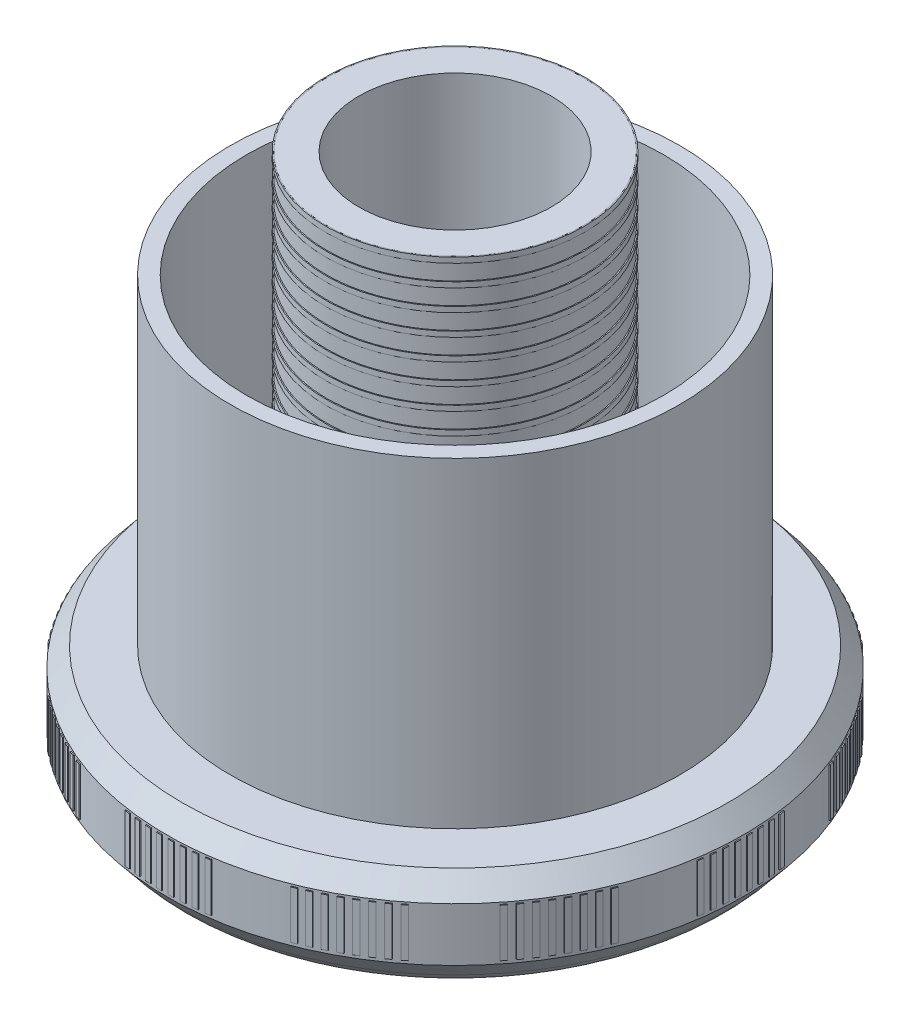
from build123d import *

# Parameters (mm, degrees)
ESQUISSE2_R                          = 12.1
ESQUISSE2_R_2                        = 12
EXTRU_MINCE1_DEPTH                   = 0.5
R_P_TITION_LIN_AIRE1_COUNT           = 19
R_P_TITION_LIN_AIRE1_PITCH           = 2
BOSS_EXTRU_1_START                   = 1.5
BOSS_EXTRU_1_DEPTH                   = 4.5
R_P_TITION_CIRCULAIRE1_COUNT         = 8
R_P_TITION_CIRCULAIRE1_ANGLE         = 16.1
R_P_TITION_CIRCULAIRE2_COUNT         = 12
R_P_TITION_START                     = 1.5
R_P_TITION_CIRCULAIRE2_COPY_1_DEPTH  = 4.5
R_P_TITION_CIRCULAIRE2_COPY_2_DEPTH  = 4.5
R_P_TITION_CIRCULAIRE2_COPY_3_DEPTH  = 4.5
R_P_TITION_CIRCULAIRE2_COPY_4_DEPTH  = 4.5
R_P_TITION_CIRCULAIRE2_COPY_5_DEPTH  = 4.5
R_P_TITION_CIRCULAIRE2_COPY_6_DEPTH  = 4.5
R_P_TITION_CIRCULAIRE2_COPY_7_DEPTH  = 4.5
R_P_TITION_CIRCULAIRE2_COPY_8_DEPTH  = 4.5
R_P_TITION_CIRCULAIRE2_COPY_9_DEPTH  = 4.5
R_P_TITION_CIRCULAIRE2_COPY_10_DEPTH = 4.5
R_P_TITION_CIRCULAIRE2_COPY_11_DEPTH = 4.5
R_P_TITION_CIRCULAIRE2_COPY_12_DEPTH = 4.5
R_P_TITION_CIRCULAIRE2_COPY_13_DEPTH = 4.5
R_P_TITION_CIRCULAIRE2_COPY_14_DEPTH = 4.5
R_P_TITION_CIRCULAIRE2_COPY_15_DEPTH = 4.5
R_P_TITION_CIRCULAIRE2_COPY_16_DEPTH = 4.5
R_P_TITION_CIRCULAIRE2_COPY_17_DEPTH = 4.5
R_P_TITION_CIRCULAIRE2_COPY_18_DEPTH = 4.5
R_P_TITION_CIRCULAIRE2_COPY_19_DEPTH = 4.5
R_P_TITION_CIRCULAIRE2_COPY_20_DEPTH = 4.5
R_P_TITION_CIRCULAIRE2_COPY_21_DEPTH = 4.5
R_P_TITION_CIRCULAIRE2_COPY_22_DEPTH = 4.5
R_P_TITION_CIRCULAIRE2_COPY_23_DEPTH = 4.5
R_P_TITION_CIRCULAIRE2_COPY_24_DEPTH = 4.5
R_P_TITION_CIRCULAIRE2_COPY_25_DEPTH = 4.5
R_P_TITION_CIRCULAIRE2_COPY_26_DEPTH = 4.5
R_P_TITION_CIRCULAIRE2_COPY_27_DEPTH = 4.5
R_P_TITION_CIRCULAIRE2_COPY_28_DEPTH = 4.5
R_P_TITION_CIRCULAIRE2_COPY_29_DEPTH = 4.5
R_P_TITION_CIRCULAIRE2_COPY_30_DEPTH = 4.5
R_P_TITION_CIRCULAIRE2_COPY_31_DEPTH = 4.5
R_P_TITION_CIRCULAIRE2_COPY_32_DEPTH = 4.5
R_P_TITION_CIRCULAIRE2_COPY_33_DEPTH = 4.5
R_P_TITION_CIRCULAIRE2_COPY_34_DEPTH = 4.5
R_P_TITION_CIRCULAIRE2_COPY_35_DEPTH = 4.5
R_P_TITION_CIRCULAIRE2_COPY_36_DEPTH = 4.5
R_P_TITION_CIRCULAIRE2_COPY_37_DEPTH = 4.5
R_P_TITION_CIRCULAIRE2_COPY_38_DEPTH = 4.5
R_P_TITION_CIRCULAIRE2_COPY_39_DEPTH = 4.5
R_P_TITION_CIRCULAIRE2_COPY_40_DEPTH = 4.5
R_P_TITION_CIRCULAIRE2_COPY_41_DEPTH = 4.5
R_P_TITION_CIRCULAIRE2_COPY_42_DEPTH = 4.5
R_P_TITION_CIRCULAIRE2_COPY_43_DEPTH = 4.5
R_P_TITION_CIRCULAIRE2_COPY_44_DEPTH = 4.5
R_P_TITION_CIRCULAIRE2_COPY_45_DEPTH = 4.5
R_P_TITION_CIRCULAIRE2_COPY_46_DEPTH = 4.5
R_P_TITION_CIRCULAIRE2_COPY_47_DEPTH = 4.5
R_P_TITION_CIRCULAIRE2_COPY_48_DEPTH = 4.5
R_P_TITION_CIRCULAIRE2_COPY_49_DEPTH = 4.5
R_P_TITION_CIRCULAIRE2_COPY_50_DEPTH = 4.5
R_P_TITION_CIRCULAIRE2_COPY_51_DEPTH = 4.5
R_P_TITION_CIRCULAIRE2_COPY_52_DEPTH = 4.5
R_P_TITION_CIRCULAIRE2_COPY_53_DEPTH = 4.5
R_P_TITION_CIRCULAIRE2_COPY_54_DEPTH = 4.5
R_P_TITION_CIRCULAIRE2_COPY_55_DEPTH = 4.5
R_P_TITION_CIRCULAIRE2_COPY_56_DEPTH = 4.5
R_P_TITION_CIRCULAIRE2_COPY_57_DEPTH = 4.5
R_P_TITION_CIRCULAIRE2_COPY_58_DEPTH = 4.5
R_P_TITION_CIRCULAIRE2_COPY_59_DEPTH = 4.5
R_P_TITION_CIRCULAIRE2_COPY_60_DEPTH = 4.5
R_P_TITION_CIRCULAIRE2_COPY_61_DEPTH = 4.5
R_P_TITION_CIRCULAIRE2_COPY_62_DEPTH = 4.5
R_P_TITION_CIRCULAIRE2_COPY_63_DEPTH = 4.5
R_P_TITION_CIRCULAIRE2_COPY_64_DEPTH = 4.5
R_P_TITION_CIRCULAIRE2_COPY_65_DEPTH = 4.5
R_P_TITION_CIRCULAIRE2_COPY_66_DEPTH = 4.5
R_P_TITION_CIRCULAIRE2_COPY_67_DEPTH = 4.5
R_P_TITION_CIRCULAIRE2_COPY_68_DEPTH = 4.5
R_P_TITION_CIRCULAIRE2_COPY_69_DEPTH = 4.5
R_P_TITION_CIRCULAIRE2_COPY_70_DEPTH = 4.5
R_P_TITION_CIRCULAIRE2_COPY_71_DEPTH = 4.5
R_P_TITION_CIRCULAIRE2_COPY_72_DEPTH = 4.5
R_P_TITION_CIRCULAIRE2_COPY_73_DEPTH = 4.5
R_P_TITION_CIRCULAIRE2_COPY_74_DEPTH = 4.5
R_P_TITION_CIRCULAIRE2_COPY_75_DEPTH = 4.5
R_P_TITION_CIRCULAIRE2_COPY_76_DEPTH = 4.5
R_P_TITION_CIRCULAIRE2_COPY_77_DEPTH = 4.5


with BuildPart() as part:
    # Esquisse1 → Révolution1 (revolve)
    with BuildSketch(Plane.XY):
        with BuildLine():
            Line((0, 0), (-5, 0))
            Line((-5, 0), (-5, 2))
            Line((-5, 2), (-9, 2))
            Line((-9, 2), (-9, -2))
            Line((-9, -2), (-21, -2))
            Line((-21, -2), (-21, 2))
            Line((-21, 2), (-23, 2))
            Line((-23, 2), (-23, -2))
            ThreePointArc((-23, -2), (-24.418637165, -1.643382037), (-25.5, -0.658312395))
            Line((-25.5, -0.658312395), (-27, 1.170843802))
            Line((-27, 1.170843802), (-27, 6.170843802))
            Line((-27, 6.170843802), (-25.5, 8))
            Line((-25.5, 8), (-21, 8))
            Line((-21, 8), (-21, 38))
            Line((-21, 38), (-19.5, 38))
            Line((-19.5, 38), (-19.5, 8))
            Line((-19.5, 8), (-12, 8))
            Line((-12, 8), (-12, 48))
            Line((-12, 48), (-9, 48))
            Line((-9, 48), (-9, 8))
            Line((-9, 8), (0, 8))
            Line((0, 8), (0, 0))
        make_face()
    revolve(axis=Axis((0, 8, 0), (0, 1, 0)))

    # Esquisse3 → Boss.-Extru.1 (add)
    with BuildSketch(Plane(origin=(0, 0, 0), x_dir=(1, 0, 0), z_dir=(0, 1, 0)).offset(BOSS_EXTRU_1_START)):
        Polygon((-3.975000726, 26.705792803), (-3.989722951, 26.804703147), (-3.494513207, 26.873748854), (-3.481618325, 26.774583729), align=None)
    boss_extru_1 = extrude(amount=BOSS_EXTRU_1_DEPTH)

    # Répétition circulaire1: Boss.-Extru.1 ×8 about axis
    r_p_tition_circulaire1_axis = Axis((0, 6.170843802, 0), (0, -1, 0))
    for i in range(1, R_P_TITION_CIRCULAIRE1_COUNT):
        add(boss_extru_1.rotate(r_p_tition_circulaire1_axis, i * R_P_TITION_CIRCULAIRE1_ANGLE / (R_P_TITION_CIRCULAIRE1_COUNT - 1)))

    # Répétition circulaire2: Boss.-Extru.1 ×12 about axis
    r_p_tition_circulaire2_axis = Axis((0, 8, 0), (0, -1, 0))
    for i in range(1, R_P_TITION_CIRCULAIRE2_COUNT):
        add(boss_extru_1.rotate(r_p_tition_circulaire2_axis, i * 360 / R_P_TITION_CIRCULAIRE2_COUNT))

    # Répétition circulaire2 copy 1 sketch → Répétition circulaire2 copy 1 (add)
    with BuildSketch(Plane(origin=(0, 0, 0), x_dir=(0.8452618332218562, 0, 0.5343523493898263), z_dir=(0, 1, 0)).offset(R_P_TITION_START)):
        Polygon((-3.975000726, 26.705792803), (-3.989722951, 26.804703147), (-3.494513207, 26.873748854), (-3.481618325, 26.774583729), align=None)
    extrude(amount=R_P_TITION_CIRCULAIRE2_COPY_1_DEPTH)

    # Répétition circulaire2 copy 2 sketch → Répétition circulaire2 copy 2 (add)
    with BuildSketch(Plane(origin=(0, 0, 0), x_dir=(0.4648420457246197, 0, 0.8853936257544158), z_dir=(0, 1, 0)).offset(R_P_TITION_START)):
        Polygon((-3.975000726, 26.705792803), (-3.989722951, 26.804703147), (-3.494513207, 26.873748854), (-3.481618325, 26.774583729), align=None)
    extrude(amount=R_P_TITION_CIRCULAIRE2_COPY_2_DEPTH)

    # Répétition circulaire2 copy 3 sketch → Répétition circulaire2 copy 3 (add)
    with BuildSketch(Plane(origin=(0, 0, 0), x_dir=(-0.04013179253255975, 0, 0.999194395114446), z_dir=(0, 1, 0)).offset(R_P_TITION_START)):
        Polygon((-3.975000726, 26.705792803), (-3.989722951, 26.804703147), (-3.494513207, 26.873748854), (-3.481618325, 26.774583729), align=None)
    extrude(amount=R_P_TITION_CIRCULAIRE2_COPY_3_DEPTH)

    # Répétition circulaire2 copy 4 sketch → Répétition circulaire2 copy 4 (add)
    with BuildSketch(Plane(origin=(0, 0, 0), x_dir=(-0.5343523493898262, 0, 0.8452618332218562), z_dir=(0, 1, 0)).offset(R_P_TITION_START)):
        Polygon((-3.975000726, 26.705792803), (-3.989722951, 26.804703147), (-3.494513207, 26.873748854), (-3.481618325, 26.774583729), align=None)
    extrude(amount=R_P_TITION_CIRCULAIRE2_COPY_4_DEPTH)

    # Répétition circulaire2 copy 5 sketch → Répétition circulaire2 copy 5 (add)
    with BuildSketch(Plane(origin=(0, 0, 0), x_dir=(-0.8853936257544159, 0, 0.4648420457246195), z_dir=(0, 1, 0)).offset(R_P_TITION_START)):
        Polygon((-3.975000726, 26.705792803), (-3.989722951, 26.804703147), (-3.494513207, 26.873748854), (-3.481618325, 26.774583729), align=None)
    extrude(amount=R_P_TITION_CIRCULAIRE2_COPY_5_DEPTH)

    # Répétition circulaire2 copy 6 sketch → Répétition circulaire2 copy 6 (add)
    with BuildSketch(Plane(origin=(0, 0, 0), x_dir=(-0.999194395114446, 0, -0.04013179253255969), z_dir=(0, 1, 0)).offset(R_P_TITION_START)):
        Polygon((-3.975000726, 26.705792803), (-3.989722951, 26.804703147), (-3.494513207, 26.873748854), (-3.481618325, 26.774583729), align=None)
    extrude(amount=R_P_TITION_CIRCULAIRE2_COPY_6_DEPTH)

    # Répétition circulaire2 copy 7 sketch → Répétition circulaire2 copy 7 (add)
    with BuildSketch(Plane(origin=(0, 0, 0), x_dir=(-0.8452618332218561, 0, -0.5343523493898266), z_dir=(0, 1, 0)).offset(R_P_TITION_START)):
        Polygon((-3.975000726, 26.705792803), (-3.989722951, 26.804703147), (-3.494513207, 26.873748854), (-3.481618325, 26.774583729), align=None)
    extrude(amount=R_P_TITION_CIRCULAIRE2_COPY_7_DEPTH)

    # Répétition circulaire2 copy 8 sketch → Répétition circulaire2 copy 8 (add)
    with BuildSketch(Plane(origin=(0, 0, 0), x_dir=(-0.46484204572462, 0, -0.8853936257544157), z_dir=(0, 1, 0)).offset(R_P_TITION_START)):
        Polygon((-3.975000726, 26.705792803), (-3.989722951, 26.804703147), (-3.494513207, 26.873748854), (-3.481618325, 26.774583729), align=None)
    extrude(amount=R_P_TITION_CIRCULAIRE2_COPY_8_DEPTH)

    # Répétition circulaire2 copy 9 sketch → Répétition circulaire2 copy 9 (add)
    with BuildSketch(Plane(origin=(0, 0, 0), x_dir=(0.040131792532559635, 0, -0.999194395114446), z_dir=(0, 1, 0)).offset(R_P_TITION_START)):
        Polygon((-3.975000726, 26.705792803), (-3.989722951, 26.804703147), (-3.494513207, 26.873748854), (-3.481618325, 26.774583729), align=None)
    extrude(amount=R_P_TITION_CIRCULAIRE2_COPY_9_DEPTH)

    # Répétition circulaire2 copy 10 sketch → Répétition circulaire2 copy 10 (add)
    with BuildSketch(Plane(origin=(0, 0, 0), x_dir=(0.5343523493898266, 0, -0.8452618332218561), z_dir=(0, 1, 0)).offset(R_P_TITION_START)):
        Polygon((-3.975000726, 26.705792803), (-3.989722951, 26.804703147), (-3.494513207, 26.873748854), (-3.481618325, 26.774583729), align=None)
    extrude(amount=R_P_TITION_CIRCULAIRE2_COPY_10_DEPTH)

    # Répétition circulaire2 copy 11 sketch → Répétition circulaire2 copy 11 (add)
    with BuildSketch(Plane(origin=(0, 0, 0), x_dir=(0.8853936257544157, 0, -0.46484204572462), z_dir=(0, 1, 0)).offset(R_P_TITION_START)):
        Polygon((-3.975000726, 26.705792803), (-3.989722951, 26.804703147), (-3.494513207, 26.873748854), (-3.481618325, 26.774583729), align=None)
    extrude(amount=R_P_TITION_CIRCULAIRE2_COPY_11_DEPTH)

    # Répétition circulaire2 copy 12 sketch → Répétition circulaire2 copy 12 (add)
    with BuildSketch(Plane(origin=(0, 0, 0), x_dir=(0.8231363685344418, 0, 0.5678437450531013), z_dir=(0, 1, 0)).offset(R_P_TITION_START)):
        Polygon((-3.975000726, 26.705792803), (-3.989722951, 26.804703147), (-3.494513207, 26.873748854), (-3.481618325, 26.774583729), align=None)
    extrude(amount=R_P_TITION_CIRCULAIRE2_COPY_12_DEPTH)

    # Répétition circulaire2 copy 13 sketch → Répétition circulaire2 copy 13 (add)
    with BuildSketch(Plane(origin=(0, 0, 0), x_dir=(0.4289351334031458, 0, 0.9033352928633007), z_dir=(0, 1, 0)).offset(R_P_TITION_START)):
        Polygon((-3.975000726, 26.705792803), (-3.989722951, 26.804703147), (-3.494513207, 26.873748854), (-3.481618325, 26.774583729), align=None)
    extrude(amount=R_P_TITION_CIRCULAIRE2_COPY_13_DEPTH)

    # Répétition circulaire2 copy 14 sketch → Répétition circulaire2 copy 14 (add)
    with BuildSketch(Plane(origin=(0, 0, 0), x_dir=(-0.08019892432885903, 0, 0.9967788784562471), z_dir=(0, 1, 0)).offset(R_P_TITION_START)):
        Polygon((-3.975000726, 26.705792803), (-3.989722951, 26.804703147), (-3.494513207, 26.873748854), (-3.481618325, 26.774583729), align=None)
    extrude(amount=R_P_TITION_CIRCULAIRE2_COPY_14_DEPTH)

    # Répétition circulaire2 copy 15 sketch → Répétition circulaire2 copy 15 (add)
    with BuildSketch(Plane(origin=(0, 0, 0), x_dir=(-0.5678437450531012, 0, 0.8231363685344418), z_dir=(0, 1, 0)).offset(R_P_TITION_START)):
        Polygon((-3.975000726, 26.705792803), (-3.989722951, 26.804703147), (-3.494513207, 26.873748854), (-3.481618325, 26.774583729), align=None)
    extrude(amount=R_P_TITION_CIRCULAIRE2_COPY_15_DEPTH)

    # Répétition circulaire2 copy 16 sketch → Répétition circulaire2 copy 16 (add)
    with BuildSketch(Plane(origin=(0, 0, 0), x_dir=(-0.9033352928633008, 0, 0.4289351334031457), z_dir=(0, 1, 0)).offset(R_P_TITION_START)):
        Polygon((-3.975000726, 26.705792803), (-3.989722951, 26.804703147), (-3.494513207, 26.873748854), (-3.481618325, 26.774583729), align=None)
    extrude(amount=R_P_TITION_CIRCULAIRE2_COPY_16_DEPTH)

    # Répétition circulaire2 copy 17 sketch → Répétition circulaire2 copy 17 (add)
    with BuildSketch(Plane(origin=(0, 0, 0), x_dir=(-0.9967788784562471, 0, -0.08019892432885896), z_dir=(0, 1, 0)).offset(R_P_TITION_START)):
        Polygon((-3.975000726, 26.705792803), (-3.989722951, 26.804703147), (-3.494513207, 26.873748854), (-3.481618325, 26.774583729), align=None)
    extrude(amount=R_P_TITION_CIRCULAIRE2_COPY_17_DEPTH)

    # Répétition circulaire2 copy 18 sketch → Répétition circulaire2 copy 18 (add)
    with BuildSketch(Plane(origin=(0, 0, 0), x_dir=(-0.8231363685344417, 0, -0.5678437450531015), z_dir=(0, 1, 0)).offset(R_P_TITION_START)):
        Polygon((-3.975000726, 26.705792803), (-3.989722951, 26.804703147), (-3.494513207, 26.873748854), (-3.481618325, 26.774583729), align=None)
    extrude(amount=R_P_TITION_CIRCULAIRE2_COPY_18_DEPTH)

    # Répétition circulaire2 copy 19 sketch → Répétition circulaire2 copy 19 (add)
    with BuildSketch(Plane(origin=(0, 0, 0), x_dir=(-0.4289351334031462, 0, -0.9033352928633006), z_dir=(0, 1, 0)).offset(R_P_TITION_START)):
        Polygon((-3.975000726, 26.705792803), (-3.989722951, 26.804703147), (-3.494513207, 26.873748854), (-3.481618325, 26.774583729), align=None)
    extrude(amount=R_P_TITION_CIRCULAIRE2_COPY_19_DEPTH)

    # Répétition circulaire2 copy 20 sketch → Répétition circulaire2 copy 20 (add)
    with BuildSketch(Plane(origin=(0, 0, 0), x_dir=(0.0801989243288589, 0, -0.9967788784562471), z_dir=(0, 1, 0)).offset(R_P_TITION_START)):
        Polygon((-3.975000726, 26.705792803), (-3.989722951, 26.804703147), (-3.494513207, 26.873748854), (-3.481618325, 26.774583729), align=None)
    extrude(amount=R_P_TITION_CIRCULAIRE2_COPY_20_DEPTH)

    # Répétition circulaire2 copy 21 sketch → Répétition circulaire2 copy 21 (add)
    with BuildSketch(Plane(origin=(0, 0, 0), x_dir=(0.5678437450531015, 0, -0.8231363685344417), z_dir=(0, 1, 0)).offset(R_P_TITION_START)):
        Polygon((-3.975000726, 26.705792803), (-3.989722951, 26.804703147), (-3.494513207, 26.873748854), (-3.481618325, 26.774583729), align=None)
    extrude(amount=R_P_TITION_CIRCULAIRE2_COPY_21_DEPTH)

    # Répétition circulaire2 copy 22 sketch → Répétition circulaire2 copy 22 (add)
    with BuildSketch(Plane(origin=(0, 0, 0), x_dir=(0.9033352928633006, 0, -0.4289351334031462), z_dir=(0, 1, 0)).offset(R_P_TITION_START)):
        Polygon((-3.975000726, 26.705792803), (-3.989722951, 26.804703147), (-3.494513207, 26.873748854), (-3.481618325, 26.774583729), align=None)
    extrude(amount=R_P_TITION_CIRCULAIRE2_COPY_22_DEPTH)

    # Répétition circulaire2 copy 23 sketch → Répétition circulaire2 copy 23 (add)
    with BuildSketch(Plane(origin=(0, 0, 0), x_dir=(0.7996846584870905, 0, 0.6004202253258842), z_dir=(0, 1, 0)).offset(R_P_TITION_START)):
        Polygon((-3.975000726, 26.705792803), (-3.989722951, 26.804703147), (-3.494513207, 26.873748854), (-3.481618325, 26.774583729), align=None)
    extrude(amount=R_P_TITION_CIRCULAIRE2_COPY_23_DEPTH)

    # Répétition circulaire2 copy 24 sketch → Répétition circulaire2 copy 24 (add)
    with BuildSketch(Plane(origin=(0, 0, 0), x_dir=(0.3923371166035614, 0, 0.9198214973217377), z_dir=(0, 1, 0)).offset(R_P_TITION_START)):
        Polygon((-3.975000726, 26.705792803), (-3.989722951, 26.804703147), (-3.494513207, 26.873748854), (-3.481618325, 26.774583729), align=None)
    extrude(amount=R_P_TITION_CIRCULAIRE2_COPY_24_DEPTH)

    # Répétition circulaire2 copy 25 sketch → Répétition circulaire2 copy 25 (add)
    with BuildSketch(Plane(origin=(0, 0, 0), x_dir=(-0.12013683883464729, 0, 0.9927573419294455), z_dir=(0, 1, 0)).offset(R_P_TITION_START)):
        Polygon((-3.975000726, 26.705792803), (-3.989722951, 26.804703147), (-3.494513207, 26.873748854), (-3.481618325, 26.774583729), align=None)
    extrude(amount=R_P_TITION_CIRCULAIRE2_COPY_25_DEPTH)

    # Répétition circulaire2 copy 26 sketch → Répétition circulaire2 copy 26 (add)
    with BuildSketch(Plane(origin=(0, 0, 0), x_dir=(-0.600420225325884, 0, 0.7996846584870905), z_dir=(0, 1, 0)).offset(R_P_TITION_START)):
        Polygon((-3.975000726, 26.705792803), (-3.989722951, 26.804703147), (-3.494513207, 26.873748854), (-3.481618325, 26.774583729), align=None)
    extrude(amount=R_P_TITION_CIRCULAIRE2_COPY_26_DEPTH)

    # Répétition circulaire2 copy 27 sketch → Répétition circulaire2 copy 27 (add)
    with BuildSketch(Plane(origin=(0, 0, 0), x_dir=(-0.9198214973217378, 0, 0.3923371166035612), z_dir=(0, 1, 0)).offset(R_P_TITION_START)):
        Polygon((-3.975000726, 26.705792803), (-3.989722951, 26.804703147), (-3.494513207, 26.873748854), (-3.481618325, 26.774583729), align=None)
    extrude(amount=R_P_TITION_CIRCULAIRE2_COPY_27_DEPTH)

    # Répétition circulaire2 copy 28 sketch → Répétition circulaire2 copy 28 (add)
    with BuildSketch(Plane(origin=(0, 0, 0), x_dir=(-0.9927573419294455, 0, -0.12013683883464722), z_dir=(0, 1, 0)).offset(R_P_TITION_START)):
        Polygon((-3.975000726, 26.705792803), (-3.989722951, 26.804703147), (-3.494513207, 26.873748854), (-3.481618325, 26.774583729), align=None)
    extrude(amount=R_P_TITION_CIRCULAIRE2_COPY_28_DEPTH)

    # Répétition circulaire2 copy 29 sketch → Répétition circulaire2 copy 29 (add)
    with BuildSketch(Plane(origin=(0, 0, 0), x_dir=(-0.7996846584870904, 0, -0.6004202253258843), z_dir=(0, 1, 0)).offset(R_P_TITION_START)):
        Polygon((-3.975000726, 26.705792803), (-3.989722951, 26.804703147), (-3.494513207, 26.873748854), (-3.481618325, 26.774583729), align=None)
    extrude(amount=R_P_TITION_CIRCULAIRE2_COPY_29_DEPTH)

    # Répétition circulaire2 copy 30 sketch → Répétition circulaire2 copy 30 (add)
    with BuildSketch(Plane(origin=(0, 0, 0), x_dir=(-0.39233711660356174, 0, -0.9198214973217376), z_dir=(0, 1, 0)).offset(R_P_TITION_START)):
        Polygon((-3.975000726, 26.705792803), (-3.989722951, 26.804703147), (-3.494513207, 26.873748854), (-3.481618325, 26.774583729), align=None)
    extrude(amount=R_P_TITION_CIRCULAIRE2_COPY_30_DEPTH)

    # Répétition circulaire2 copy 31 sketch → Répétition circulaire2 copy 31 (add)
    with BuildSketch(Plane(origin=(0, 0, 0), x_dir=(0.12013683883464717, 0, -0.9927573419294455), z_dir=(0, 1, 0)).offset(R_P_TITION_START)):
        Polygon((-3.975000726, 26.705792803), (-3.989722951, 26.804703147), (-3.494513207, 26.873748854), (-3.481618325, 26.774583729), align=None)
    extrude(amount=R_P_TITION_CIRCULAIRE2_COPY_31_DEPTH)

    # Répétition circulaire2 copy 32 sketch → Répétition circulaire2 copy 32 (add)
    with BuildSketch(Plane(origin=(0, 0, 0), x_dir=(0.6004202253258843, 0, -0.7996846584870904), z_dir=(0, 1, 0)).offset(R_P_TITION_START)):
        Polygon((-3.975000726, 26.705792803), (-3.989722951, 26.804703147), (-3.494513207, 26.873748854), (-3.481618325, 26.774583729), align=None)
    extrude(amount=R_P_TITION_CIRCULAIRE2_COPY_32_DEPTH)

    # Répétition circulaire2 copy 33 sketch → Répétition circulaire2 copy 33 (add)
    with BuildSketch(Plane(origin=(0, 0, 0), x_dir=(0.9198214973217376, 0, -0.39233711660356174), z_dir=(0, 1, 0)).offset(R_P_TITION_START)):
        Polygon((-3.975000726, 26.705792803), (-3.989722951, 26.804703147), (-3.494513207, 26.873748854), (-3.481618325, 26.774583729), align=None)
    extrude(amount=R_P_TITION_CIRCULAIRE2_COPY_33_DEPTH)

    # Répétition circulaire2 copy 34 sketch → Répétition circulaire2 copy 34 (add)
    with BuildSketch(Plane(origin=(0, 0, 0), x_dir=(0.7749444887041795, 0, 0.6320293026648511), z_dir=(0, 1, 0)).offset(R_P_TITION_START)):
        Polygon((-3.975000726, 26.705792803), (-3.989722951, 26.804703147), (-3.494513207, 26.873748854), (-3.481618325, 26.774583729), align=None)
    extrude(amount=R_P_TITION_CIRCULAIRE2_COPY_34_DEPTH)

    # Répétition circulaire2 copy 35 sketch → Répétition circulaire2 copy 35 (add)
    with BuildSketch(Plane(origin=(0, 0, 0), x_dir=(0.3551069624081369, 0, 0.9348256763960145), z_dir=(0, 1, 0)).offset(R_P_TITION_START)):
        Polygon((-3.975000726, 26.705792803), (-3.989722951, 26.804703147), (-3.494513207, 26.873748854), (-3.481618325, 26.774583729), align=None)
    extrude(amount=R_P_TITION_CIRCULAIRE2_COPY_35_DEPTH)

    # Répétition circulaire2 copy 36 sketch → Répétition circulaire2 copy 36 (add)
    with BuildSketch(Plane(origin=(0, 0, 0), x_dir=(-0.15988118769183512, 0, 0.9871362650729879), z_dir=(0, 1, 0)).offset(R_P_TITION_START)):
        Polygon((-3.975000726, 26.705792803), (-3.989722951, 26.804703147), (-3.494513207, 26.873748854), (-3.481618325, 26.774583729), align=None)
    extrude(amount=R_P_TITION_CIRCULAIRE2_COPY_36_DEPTH)

    # Répétition circulaire2 copy 37 sketch → Répétition circulaire2 copy 37 (add)
    with BuildSketch(Plane(origin=(0, 0, 0), x_dir=(-0.6320293026648509, 0, 0.7749444887041795), z_dir=(0, 1, 0)).offset(R_P_TITION_START)):
        Polygon((-3.975000726, 26.705792803), (-3.989722951, 26.804703147), (-3.494513207, 26.873748854), (-3.481618325, 26.774583729), align=None)
    extrude(amount=R_P_TITION_CIRCULAIRE2_COPY_37_DEPTH)

    # Répétition circulaire2 copy 38 sketch → Répétition circulaire2 copy 38 (add)
    with BuildSketch(Plane(origin=(0, 0, 0), x_dir=(-0.9348256763960147, 0, 0.3551069624081367), z_dir=(0, 1, 0)).offset(R_P_TITION_START)):
        Polygon((-3.975000726, 26.705792803), (-3.989722951, 26.804703147), (-3.494513207, 26.873748854), (-3.481618325, 26.774583729), align=None)
    extrude(amount=R_P_TITION_CIRCULAIRE2_COPY_38_DEPTH)

    # Répétition circulaire2 copy 39 sketch → Répétition circulaire2 copy 39 (add)
    with BuildSketch(Plane(origin=(0, 0, 0), x_dir=(-0.9871362650729879, 0, -0.15988118769183507), z_dir=(0, 1, 0)).offset(R_P_TITION_START)):
        Polygon((-3.975000726, 26.705792803), (-3.989722951, 26.804703147), (-3.494513207, 26.873748854), (-3.481618325, 26.774583729), align=None)
    extrude(amount=R_P_TITION_CIRCULAIRE2_COPY_39_DEPTH)

    # Répétition circulaire2 copy 40 sketch → Répétition circulaire2 copy 40 (add)
    with BuildSketch(Plane(origin=(0, 0, 0), x_dir=(-0.7749444887041794, 0, -0.6320293026648512), z_dir=(0, 1, 0)).offset(R_P_TITION_START)):
        Polygon((-3.975000726, 26.705792803), (-3.989722951, 26.804703147), (-3.494513207, 26.873748854), (-3.481618325, 26.774583729), align=None)
    extrude(amount=R_P_TITION_CIRCULAIRE2_COPY_40_DEPTH)

    # Répétition circulaire2 copy 41 sketch → Répétition circulaire2 copy 41 (add)
    with BuildSketch(Plane(origin=(0, 0, 0), x_dir=(-0.3551069624081372, 0, -0.9348256763960144), z_dir=(0, 1, 0)).offset(R_P_TITION_START)):
        Polygon((-3.975000726, 26.705792803), (-3.989722951, 26.804703147), (-3.494513207, 26.873748854), (-3.481618325, 26.774583729), align=None)
    extrude(amount=R_P_TITION_CIRCULAIRE2_COPY_41_DEPTH)

    # Répétition circulaire2 copy 42 sketch → Répétition circulaire2 copy 42 (add)
    with BuildSketch(Plane(origin=(0, 0, 0), x_dir=(0.159881187691835, 0, -0.9871362650729879), z_dir=(0, 1, 0)).offset(R_P_TITION_START)):
        Polygon((-3.975000726, 26.705792803), (-3.989722951, 26.804703147), (-3.494513207, 26.873748854), (-3.481618325, 26.774583729), align=None)
    extrude(amount=R_P_TITION_CIRCULAIRE2_COPY_42_DEPTH)

    # Répétition circulaire2 copy 43 sketch → Répétition circulaire2 copy 43 (add)
    with BuildSketch(Plane(origin=(0, 0, 0), x_dir=(0.6320293026648512, 0, -0.7749444887041794), z_dir=(0, 1, 0)).offset(R_P_TITION_START)):
        Polygon((-3.975000726, 26.705792803), (-3.989722951, 26.804703147), (-3.494513207, 26.873748854), (-3.481618325, 26.774583729), align=None)
    extrude(amount=R_P_TITION_CIRCULAIRE2_COPY_43_DEPTH)

    # Répétition circulaire2 copy 44 sketch → Répétition circulaire2 copy 44 (add)
    with BuildSketch(Plane(origin=(0, 0, 0), x_dir=(0.9348256763960144, 0, -0.3551069624081372), z_dir=(0, 1, 0)).offset(R_P_TITION_START)):
        Polygon((-3.975000726, 26.705792803), (-3.989722951, 26.804703147), (-3.494513207, 26.873748854), (-3.481618325, 26.774583729), align=None)
    extrude(amount=R_P_TITION_CIRCULAIRE2_COPY_44_DEPTH)

    # Répétition circulaire2 copy 45 sketch → Répétition circulaire2 copy 45 (add)
    with BuildSketch(Plane(origin=(0, 0, 0), x_dir=(0.7489557207890021, 0, 0.6626200482157377), z_dir=(0, 1, 0)).offset(R_P_TITION_START)):
        Polygon((-3.975000726, 26.705792803), (-3.989722951, 26.804703147), (-3.494513207, 26.873748854), (-3.481618325, 26.774583729), align=None)
    extrude(amount=R_P_TITION_CIRCULAIRE2_COPY_45_DEPTH)

    # Répétition circulaire2 copy 46 sketch → Répétition circulaire2 copy 46 (add)
    with BuildSketch(Plane(origin=(0, 0, 0), x_dir=(0.3173046564050919, 0, 0.9483236552061995), z_dir=(0, 1, 0)).offset(R_P_TITION_START)):
        Polygon((-3.975000726, 26.705792803), (-3.989722951, 26.804703147), (-3.494513207, 26.873748854), (-3.481618325, 26.774583729), align=None)
    extrude(amount=R_P_TITION_CIRCULAIRE2_COPY_46_DEPTH)

    # Répétition circulaire2 copy 47 sketch → Répétition circulaire2 copy 47 (add)
    with BuildSketch(Plane(origin=(0, 0, 0), x_dir=(-0.1993679344171975, 0, 0.9799247046208296), z_dir=(0, 1, 0)).offset(R_P_TITION_START)):
        Polygon((-3.975000726, 26.705792803), (-3.989722951, 26.804703147), (-3.494513207, 26.873748854), (-3.481618325, 26.774583729), align=None)
    extrude(amount=R_P_TITION_CIRCULAIRE2_COPY_47_DEPTH)

    # Répétition circulaire2 copy 48 sketch → Répétition circulaire2 copy 48 (add)
    with BuildSketch(Plane(origin=(0, 0, 0), x_dir=(-0.6626200482157376, 0, 0.7489557207890021), z_dir=(0, 1, 0)).offset(R_P_TITION_START)):
        Polygon((-3.975000726, 26.705792803), (-3.989722951, 26.804703147), (-3.494513207, 26.873748854), (-3.481618325, 26.774583729), align=None)
    extrude(amount=R_P_TITION_CIRCULAIRE2_COPY_48_DEPTH)

    # Répétition circulaire2 copy 49 sketch → Répétition circulaire2 copy 49 (add)
    with BuildSketch(Plane(origin=(0, 0, 0), x_dir=(-0.9483236552061995, 0, 0.31730465640509176), z_dir=(0, 1, 0)).offset(R_P_TITION_START)):
        Polygon((-3.975000726, 26.705792803), (-3.989722951, 26.804703147), (-3.494513207, 26.873748854), (-3.481618325, 26.774583729), align=None)
    extrude(amount=R_P_TITION_CIRCULAIRE2_COPY_49_DEPTH)

    # Répétition circulaire2 copy 50 sketch → Répétition circulaire2 copy 50 (add)
    with BuildSketch(Plane(origin=(0, 0, 0), x_dir=(-0.9799247046208296, 0, -0.19936793441719744), z_dir=(0, 1, 0)).offset(R_P_TITION_START)):
        Polygon((-3.975000726, 26.705792803), (-3.989722951, 26.804703147), (-3.494513207, 26.873748854), (-3.481618325, 26.774583729), align=None)
    extrude(amount=R_P_TITION_CIRCULAIRE2_COPY_50_DEPTH)

    # Répétition circulaire2 copy 51 sketch → Répétition circulaire2 copy 51 (add)
    with BuildSketch(Plane(origin=(0, 0, 0), x_dir=(-0.7489557207890019, 0, -0.6626200482157378), z_dir=(0, 1, 0)).offset(R_P_TITION_START)):
        Polygon((-3.975000726, 26.705792803), (-3.989722951, 26.804703147), (-3.494513207, 26.873748854), (-3.481618325, 26.774583729), align=None)
    extrude(amount=R_P_TITION_CIRCULAIRE2_COPY_51_DEPTH)

    # Répétition circulaire2 copy 52 sketch → Répétition circulaire2 copy 52 (add)
    with BuildSketch(Plane(origin=(0, 0, 0), x_dir=(-0.3173046564050923, 0, -0.9483236552061993), z_dir=(0, 1, 0)).offset(R_P_TITION_START)):
        Polygon((-3.975000726, 26.705792803), (-3.989722951, 26.804703147), (-3.494513207, 26.873748854), (-3.481618325, 26.774583729), align=None)
    extrude(amount=R_P_TITION_CIRCULAIRE2_COPY_52_DEPTH)

    # Répétition circulaire2 copy 53 sketch → Répétition circulaire2 copy 53 (add)
    with BuildSketch(Plane(origin=(0, 0, 0), x_dir=(0.19936793441719738, 0, -0.9799247046208296), z_dir=(0, 1, 0)).offset(R_P_TITION_START)):
        Polygon((-3.975000726, 26.705792803), (-3.989722951, 26.804703147), (-3.494513207, 26.873748854), (-3.481618325, 26.774583729), align=None)
    extrude(amount=R_P_TITION_CIRCULAIRE2_COPY_53_DEPTH)

    # Répétition circulaire2 copy 54 sketch → Répétition circulaire2 copy 54 (add)
    with BuildSketch(Plane(origin=(0, 0, 0), x_dir=(0.6626200482157378, 0, -0.7489557207890019), z_dir=(0, 1, 0)).offset(R_P_TITION_START)):
        Polygon((-3.975000726, 26.705792803), (-3.989722951, 26.804703147), (-3.494513207, 26.873748854), (-3.481618325, 26.774583729), align=None)
    extrude(amount=R_P_TITION_CIRCULAIRE2_COPY_54_DEPTH)

    # Répétition circulaire2 copy 55 sketch → Répétition circulaire2 copy 55 (add)
    with BuildSketch(Plane(origin=(0, 0, 0), x_dir=(0.9483236552061993, 0, -0.3173046564050923), z_dir=(0, 1, 0)).offset(R_P_TITION_START)):
        Polygon((-3.975000726, 26.705792803), (-3.989722951, 26.804703147), (-3.494513207, 26.873748854), (-3.481618325, 26.774583729), align=None)
    extrude(amount=R_P_TITION_CIRCULAIRE2_COPY_55_DEPTH)

    # Répétition circulaire2 copy 56 sketch → Répétition circulaire2 copy 56 (add)
    with BuildSketch(Plane(origin=(0, 0, 0), x_dir=(0.7217602280983619, 0, 0.6921431738704071), z_dir=(0, 1, 0)).offset(R_P_TITION_START)):
        Polygon((-3.975000726, 26.705792803), (-3.989722951, 26.804703147), (-3.494513207, 26.873748854), (-3.481618325, 26.774583729), align=None)
    extrude(amount=R_P_TITION_CIRCULAIRE2_COPY_56_DEPTH)

    # Répétition circulaire2 copy 57 sketch → Répétition circulaire2 copy 57 (add)
    with BuildSketch(Plane(origin=(0, 0, 0), x_dir=(0.27899110603922894, 0, 0.9602936856769432), z_dir=(0, 1, 0)).offset(R_P_TITION_START)):
        Polygon((-3.975000726, 26.705792803), (-3.989722951, 26.804703147), (-3.494513207, 26.873748854), (-3.481618325, 26.774583729), align=None)
    extrude(amount=R_P_TITION_CIRCULAIRE2_COPY_57_DEPTH)

    # Répétition circulaire2 copy 58 sketch → Répétition circulaire2 copy 58 (add)
    with BuildSketch(Plane(origin=(0, 0, 0), x_dir=(-0.2385334575785813, 0, 0.971134279909636), z_dir=(0, 1, 0)).offset(R_P_TITION_START)):
        Polygon((-3.975000726, 26.705792803), (-3.989722951, 26.804703147), (-3.494513207, 26.873748854), (-3.481618325, 26.774583729), align=None)
    extrude(amount=R_P_TITION_CIRCULAIRE2_COPY_58_DEPTH)

    # Répétition circulaire2 copy 59 sketch → Répétition circulaire2 copy 59 (add)
    with BuildSketch(Plane(origin=(0, 0, 0), x_dir=(-0.6921431738704069, 0, 0.7217602280983619), z_dir=(0, 1, 0)).offset(R_P_TITION_START)):
        Polygon((-3.975000726, 26.705792803), (-3.989722951, 26.804703147), (-3.494513207, 26.873748854), (-3.481618325, 26.774583729), align=None)
    extrude(amount=R_P_TITION_CIRCULAIRE2_COPY_59_DEPTH)

    # Répétition circulaire2 copy 60 sketch → Répétition circulaire2 copy 60 (add)
    with BuildSketch(Plane(origin=(0, 0, 0), x_dir=(-0.9602936856769433, 0, 0.2789911060392287), z_dir=(0, 1, 0)).offset(R_P_TITION_START)):
        Polygon((-3.975000726, 26.705792803), (-3.989722951, 26.804703147), (-3.494513207, 26.873748854), (-3.481618325, 26.774583729), align=None)
    extrude(amount=R_P_TITION_CIRCULAIRE2_COPY_60_DEPTH)

    # Répétition circulaire2 copy 61 sketch → Répétition circulaire2 copy 61 (add)
    with BuildSketch(Plane(origin=(0, 0, 0), x_dir=(-0.971134279909636, 0, -0.23853345757858124), z_dir=(0, 1, 0)).offset(R_P_TITION_START)):
        Polygon((-3.975000726, 26.705792803), (-3.989722951, 26.804703147), (-3.494513207, 26.873748854), (-3.481618325, 26.774583729), align=None)
    extrude(amount=R_P_TITION_CIRCULAIRE2_COPY_61_DEPTH)

    # Répétition circulaire2 copy 62 sketch → Répétition circulaire2 copy 62 (add)
    with BuildSketch(Plane(origin=(0, 0, 0), x_dir=(-0.7217602280983618, 0, -0.6921431738704072), z_dir=(0, 1, 0)).offset(R_P_TITION_START)):
        Polygon((-3.975000726, 26.705792803), (-3.989722951, 26.804703147), (-3.494513207, 26.873748854), (-3.481618325, 26.774583729), align=None)
    extrude(amount=R_P_TITION_CIRCULAIRE2_COPY_62_DEPTH)

    # Répétition circulaire2 copy 63 sketch → Répétition circulaire2 copy 63 (add)
    with BuildSketch(Plane(origin=(0, 0, 0), x_dir=(-0.2789911060392293, 0, -0.9602936856769431), z_dir=(0, 1, 0)).offset(R_P_TITION_START)):
        Polygon((-3.975000726, 26.705792803), (-3.989722951, 26.804703147), (-3.494513207, 26.873748854), (-3.481618325, 26.774583729), align=None)
    extrude(amount=R_P_TITION_CIRCULAIRE2_COPY_63_DEPTH)

    # Répétition circulaire2 copy 64 sketch → Répétition circulaire2 copy 64 (add)
    with BuildSketch(Plane(origin=(0, 0, 0), x_dir=(0.2385334575785812, 0, -0.971134279909636), z_dir=(0, 1, 0)).offset(R_P_TITION_START)):
        Polygon((-3.975000726, 26.705792803), (-3.989722951, 26.804703147), (-3.494513207, 26.873748854), (-3.481618325, 26.774583729), align=None)
    extrude(amount=R_P_TITION_CIRCULAIRE2_COPY_64_DEPTH)

    # Répétition circulaire2 copy 65 sketch → Répétition circulaire2 copy 65 (add)
    with BuildSketch(Plane(origin=(0, 0, 0), x_dir=(0.6921431738704072, 0, -0.7217602280983618), z_dir=(0, 1, 0)).offset(R_P_TITION_START)):
        Polygon((-3.975000726, 26.705792803), (-3.989722951, 26.804703147), (-3.494513207, 26.873748854), (-3.481618325, 26.774583729), align=None)
    extrude(amount=R_P_TITION_CIRCULAIRE2_COPY_65_DEPTH)

    # Répétition circulaire2 copy 66 sketch → Répétition circulaire2 copy 66 (add)
    with BuildSketch(Plane(origin=(0, 0, 0), x_dir=(0.9602936856769431, 0, -0.2789911060392293), z_dir=(0, 1, 0)).offset(R_P_TITION_START)):
        Polygon((-3.975000726, 26.705792803), (-3.989722951, 26.804703147), (-3.494513207, 26.873748854), (-3.481618325, 26.774583729), align=None)
    extrude(amount=R_P_TITION_CIRCULAIRE2_COPY_66_DEPTH)

    # Répétition circulaire2 copy 67 sketch → Répétition circulaire2 copy 67 (add)
    with BuildSketch(Plane(origin=(0, 0, 0), x_dir=(0.6934018282758126, 0, 0.7205511116803307), z_dir=(0, 1, 0)).offset(R_P_TITION_START)):
        Polygon((-3.975000726, 26.705792803), (-3.989722951, 26.804703147), (-3.494513207, 26.873748854), (-3.481618325, 26.774583729), align=None)
    extrude(amount=R_P_TITION_CIRCULAIRE2_COPY_67_DEPTH)

    # Répétition circulaire2 copy 68 sketch → Répétition circulaire2 copy 68 (add)
    with BuildSketch(Plane(origin=(0, 0, 0), x_dir=(0.24022804247726331, 0, 0.9707164815781908), z_dir=(0, 1, 0)).offset(R_P_TITION_START)):
        Polygon((-3.975000726, 26.705792803), (-3.989722951, 26.804703147), (-3.494513207, 26.873748854), (-3.481618325, 26.774583729), align=None)
    extrude(amount=R_P_TITION_CIRCULAIRE2_COPY_68_DEPTH)

    # Répétition circulaire2 copy 69 sketch → Répétition circulaire2 copy 69 (add)
    with BuildSketch(Plane(origin=(0, 0, 0), x_dir=(-0.27731465330237826, 0, 0.960779154157594), z_dir=(0, 1, 0)).offset(R_P_TITION_START)):
        Polygon((-3.975000726, 26.705792803), (-3.989722951, 26.804703147), (-3.494513207, 26.873748854), (-3.481618325, 26.774583729), align=None)
    extrude(amount=R_P_TITION_CIRCULAIRE2_COPY_69_DEPTH)

    # Répétition circulaire2 copy 70 sketch → Répétition circulaire2 copy 70 (add)
    with BuildSketch(Plane(origin=(0, 0, 0), x_dir=(-0.7205511116803306, 0, 0.6934018282758126), z_dir=(0, 1, 0)).offset(R_P_TITION_START)):
        Polygon((-3.975000726, 26.705792803), (-3.989722951, 26.804703147), (-3.494513207, 26.873748854), (-3.481618325, 26.774583729), align=None)
    extrude(amount=R_P_TITION_CIRCULAIRE2_COPY_70_DEPTH)

    # Répétition circulaire2 copy 71 sketch → Répétition circulaire2 copy 71 (add)
    with BuildSketch(Plane(origin=(0, 0, 0), x_dir=(-0.9707164815781909, 0, 0.24022804247726312), z_dir=(0, 1, 0)).offset(R_P_TITION_START)):
        Polygon((-3.975000726, 26.705792803), (-3.989722951, 26.804703147), (-3.494513207, 26.873748854), (-3.481618325, 26.774583729), align=None)
    extrude(amount=R_P_TITION_CIRCULAIRE2_COPY_71_DEPTH)

    # Répétition circulaire2 copy 72 sketch → Répétition circulaire2 copy 72 (add)
    with BuildSketch(Plane(origin=(0, 0, 0), x_dir=(-0.960779154157594, 0, -0.2773146533023782), z_dir=(0, 1, 0)).offset(R_P_TITION_START)):
        Polygon((-3.975000726, 26.705792803), (-3.989722951, 26.804703147), (-3.494513207, 26.873748854), (-3.481618325, 26.774583729), align=None)
    extrude(amount=R_P_TITION_CIRCULAIRE2_COPY_72_DEPTH)

    # Répétition circulaire2 copy 73 sketch → Répétition circulaire2 copy 73 (add)
    with BuildSketch(Plane(origin=(0, 0, 0), x_dir=(-0.6934018282758125, 0, -0.7205511116803309), z_dir=(0, 1, 0)).offset(R_P_TITION_START)):
        Polygon((-3.975000726, 26.705792803), (-3.989722951, 26.804703147), (-3.494513207, 26.873748854), (-3.481618325, 26.774583729), align=None)
    extrude(amount=R_P_TITION_CIRCULAIRE2_COPY_73_DEPTH)

    # Répétition circulaire2 copy 74 sketch → Répétition circulaire2 copy 74 (add)
    with BuildSketch(Plane(origin=(0, 0, 0), x_dir=(-0.2402280424772637, 0, -0.9707164815781907), z_dir=(0, 1, 0)).offset(R_P_TITION_START)):
        Polygon((-3.975000726, 26.705792803), (-3.989722951, 26.804703147), (-3.494513207, 26.873748854), (-3.481618325, 26.774583729), align=None)
    extrude(amount=R_P_TITION_CIRCULAIRE2_COPY_74_DEPTH)

    # Répétition circulaire2 copy 75 sketch → Répétition circulaire2 copy 75 (add)
    with BuildSketch(Plane(origin=(0, 0, 0), x_dir=(0.27731465330237814, 0, -0.960779154157594), z_dir=(0, 1, 0)).offset(R_P_TITION_START)):
        Polygon((-3.975000726, 26.705792803), (-3.989722951, 26.804703147), (-3.494513207, 26.873748854), (-3.481618325, 26.774583729), align=None)
    extrude(amount=R_P_TITION_CIRCULAIRE2_COPY_75_DEPTH)

    # Répétition circulaire2 copy 76 sketch → Répétition circulaire2 copy 76 (add)
    with BuildSketch(Plane(origin=(0, 0, 0), x_dir=(0.7205511116803309, 0, -0.6934018282758125), z_dir=(0, 1, 0)).offset(R_P_TITION_START)):
        Polygon((-3.975000726, 26.705792803), (-3.989722951, 26.804703147), (-3.494513207, 26.873748854), (-3.481618325, 26.774583729), align=None)
    extrude(amount=R_P_TITION_CIRCULAIRE2_COPY_76_DEPTH)

    # Répétition circulaire2 copy 77 sketch → Répétition circulaire2 copy 77 (add)
    with BuildSketch(Plane(origin=(0, 0, 0), x_dir=(0.9707164815781907, 0, -0.2402280424772637), z_dir=(0, 1, 0)).offset(R_P_TITION_START)):
        Polygon((-3.975000726, 26.705792803), (-3.989722951, 26.804703147), (-3.494513207, 26.873748854), (-3.481618325, 26.774583729), align=None)
    extrude(amount=R_P_TITION_CIRCULAIRE2_COPY_77_DEPTH)


with BuildPart() as body_2:
    # Esquisse2 → Extru.-Mince1 (new body)
    with BuildSketch(Plane(origin=(0, 48, 0), x_dir=(1, 0, 0), z_dir=(0, 1, 0))):
        Circle(ESQUISSE2_R)
        Circle(ESQUISSE2_R_2, mode=Mode.SUBTRACT)
    extru_mince1 = extrude(amount=-EXTRU_MINCE1_DEPTH)


with BuildPart() as r_p_tition_lin_aire1_1:
    # Répétition linéaire1: Extru.-Mince1 ×19
    with Locations(*[(0, -i * R_P_TITION_LIN_AIRE1_PITCH, 0) for i in range(1, R_P_TITION_LIN_AIRE1_COUNT)]):
        add(extru_mince1)


solid = Compound([part.part, body_2.part, r_p_tition_lin_aire1_1.part])
